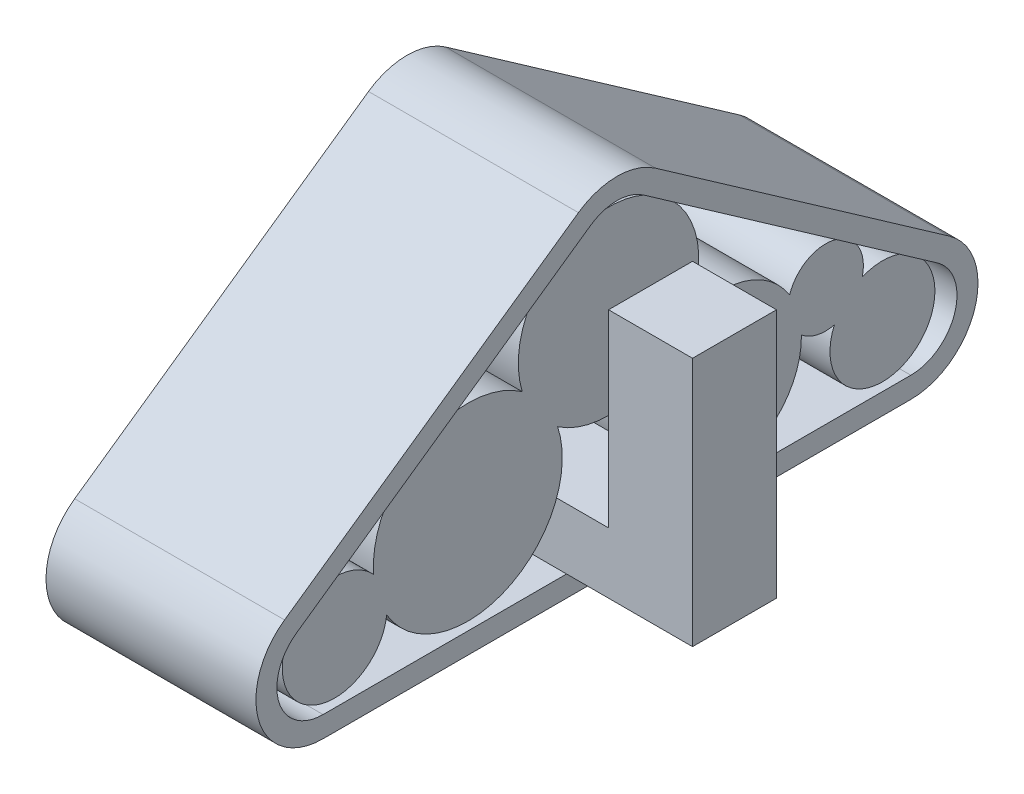
from build123d import *

# Parameters (mm, degrees)
TREADS_DEPTH                   = 2.5
CIRCLES_DEPTH                  = 1.15
CIRCLES_DEPTH_BACK             = 1.15
BOTTOM_OF_CONNECTOR_DEPTH      = 2.75
BOTTOM_OF_CONNECTOR_DEPTH_BACK = 1.25
SKETCH3_5_W                    = 1
SKETCH3_5_H                    = 0.725
SKETCH4_W                      = 1
SKETCH4_H                      = 1
TOP_OF_CONNECTOR_DEPTH         = 2.25
SCALE1_SCALE                   = 1.8


with BuildPart() as part:
    # Sketch1 → Treads (new body)
    with BuildSketch(Plane(origin=(0, 0, 0), x_dir=(0, 0, -1), z_dir=(1, 0, 0))):
        with BuildLine():
            Line((-3, 0), (3, 0))
            Line((3, 0), (3.5, 0))
            ThreePointArc((3.5, 0), (4.262973561, 0.55943536), (3.958861149, 1.455321635))
            Line((3.958861149, 1.455321635), (0.458861149, 3.906048019))
            ThreePointArc((0.458861149, 3.906048019), (0, 4.050726384), (-0.458861149, 3.906048019))
            Line((-0.458861149, 3.906048019), (-3.958861149, 1.455321635))
            ThreePointArc((-3.958861149, 1.455321635), (-4.262973561, 0.55943536), (-3.5, 0))
            Line((-3.5, 0), (-3, 0))
        make_face()
        with BuildLine():
            ThreePointArc((0, 3.800726384), (0.16538819, 3.775270707), (0.31546704, 3.701260008))
            Line((0.31546704, 3.701260008), (3.81546704, 1.250533624))
            ThreePointArc((3.81546704, 1.250533624), (4.024544323, 0.63461181), (3.5, 0.25))
            Line((3.5, 0.25), (-3.5, 0.25))
            ThreePointArc((-3.5, 0.25), (-4.024544323, 0.63461181), (-3.81546704, 1.250533624))
            Line((-3.81546704, 1.250533624), (-0.31546704, 3.701260008))
            ThreePointArc((-0.31546704, 3.701260008), (-0.16538819, 3.775270707), (0, 3.800726384))
        make_face(mode=Mode.SUBTRACT)
    extrude(amount=TREADS_DEPTH)

    # Sketch3_5 → Bottom of Connector (add, two sides: drawn at the far end of the back side and taken through both)
    with BuildSketch(Plane(origin=(1.25, 0, 0), x_dir=(0, 0, -1), z_dir=(1, 0, 0)).offset(-BOTTOM_OF_CONNECTOR_DEPTH_BACK)):
        with Locations((-0.1, 0.6125)):
            Rectangle(SKETCH3_5_W, SKETCH3_5_H)
    extrude(amount=BOTTOM_OF_CONNECTOR_DEPTH + BOTTOM_OF_CONNECTOR_DEPTH_BACK)

    # Sketch4 → Top of Connector (add)
    with BuildSketch(Plane(origin=(0, 0.975, 0), x_dir=(1, 0, 0), z_dir=(0, 1, 0))):
        with Locations((3.5, -0.1)):
            Rectangle(SKETCH4_W, SKETCH4_H)
    extrude(amount=TOP_OF_CONNECTOR_DEPTH)


with BuildPart() as body_2:
    # Sketch3 → Circles (new, two sides: drawn at the far end of the back side and taken through both)
    with BuildSketch(Plane(origin=(1.25, 0, 0), x_dir=(0, 0, -1), z_dir=(1, 0, 0)).offset(-CIRCLES_DEPTH_BACK)):
        with BuildLine():
            ThreePointArc((-2.641926718, 0.797718657), (-1.211224345, 0.350647058), (-0.606199298, 1.722043057))
            ThreePointArc((-0.606199298, 1.722043057), (-0.049783758, 1.535973098), (0.521460622, 1.669764503))
            ThreePointArc((0.521460622, 1.669764503), (1.112446431, 0.279457962), (2.297033365, 1.216992122))
            ThreePointArc((2.297033365, 1.216992122), (2.482253195, 1.124579804), (2.68924678, 1.124858699))
            ThreePointArc((2.68924678, 1.124858699), (3.700598319, 0.429611546), (3.021273042, 1.451725878))
            ThreePointArc((3.021273042, 1.451725878), (2.708453629, 1.995435529), (2.15606319, 1.698213434))
            ThreePointArc((2.15606319, 1.698213434), (1.60374964, 2.114699273), (0.915404217, 2.046206275))
            ThreePointArc((0.915404217, 2.046206275), (0.136054833, 3.676175239), (-1.027595727, 2.294110965))
            ThreePointArc((-1.027595727, 2.294110965), (-2.229550715, 2.354579066), (-2.798416042, 1.294039382))
            ThreePointArc((-2.798416042, 1.294039382), (-3.858203484, 0.687058875), (-2.641926718, 0.797718657))
        make_face()
    extrude(amount=CIRCLES_DEPTH + CIRCLES_DEPTH_BACK)


with BuildPart() as part_1:
    # Scale1: scaled about (0, 0, 0)
    add(part.part.scale(SCALE1_SCALE))


with BuildPart() as body_2_1:
    # Scale1: scaled about (0, 0, 0)
    add(body_2.part.scale(SCALE1_SCALE))


solid = Compound([part_1.part, body_2_1.part])
